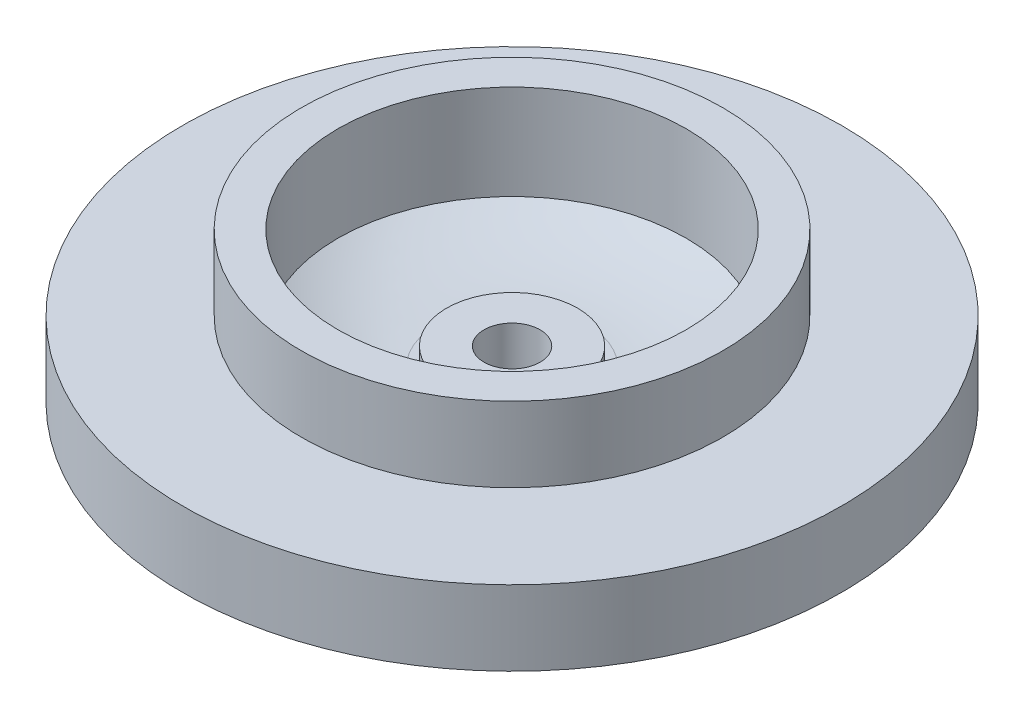
from build123d import *

# Parameters (mm, degrees)
SKETCH2_R          = 1.5
CUT_EXTRUDE1_DEPTH = 10


with BuildPart() as part:
    # Sketch1 → Revolve1 (revolve)
    with BuildSketch(Plane.XY):
        with BuildLine():
            Line((-17.6, 1.5), (-17.6, 5.5))
            Line((-17.6, 5.5), (-11.25, 5.5))
            Line((-11.25, 5.5), (-11.25, 9.5))
            Line((-11.25, 9.5), (-9.3, 9.5))
            Line((-9.3, 9.5), (-9.3, 4.435928697))
            ThreePointArc((-9.3, 4.435928697), (-6.732887918, 3.439124969), (-4, 3.1))
            Line((-4, 3.1), (-3.5, 3.1))
            Line((-3.5, 3.1), (-3.5, 4.1))
            Line((-3.5, 4.1), (0, 4.1))
            Line((0, 4.1), (0, 0))
            Line((0, 0), (-4, 0))
            Line((-4, 0), (-4, 2.5))
            ThreePointArc((-4, 2.5), (-6.42706098, 2.752710346), (-8.75, 3.5))
            Line((-8.75, 3.5), (-8.75, 0))
            Line((-8.75, 0), (-13.5, 0))
            Line((-13.5, 0), (-13.5, 3))
            Line((-13.5, 3), (-16.6, 3))
            Line((-16.6, 3), (-16.6, 1.5))
            Line((-16.6, 1.5), (-17.6, 1.5))
        make_face()
    revolve(axis=Axis((0, 0, 0), (0, 1, 0)))

    # Sketch2 → Cut-Extrude1 (cut)
    with BuildSketch(Plane(origin=(0, 4.1, 0), x_dir=(1, 0, 0), z_dir=(0, 1, 0))):
        Circle(SKETCH2_R)
    extrude(amount=-CUT_EXTRUDE1_DEPTH, mode=Mode.SUBTRACT)


solid = part.part
